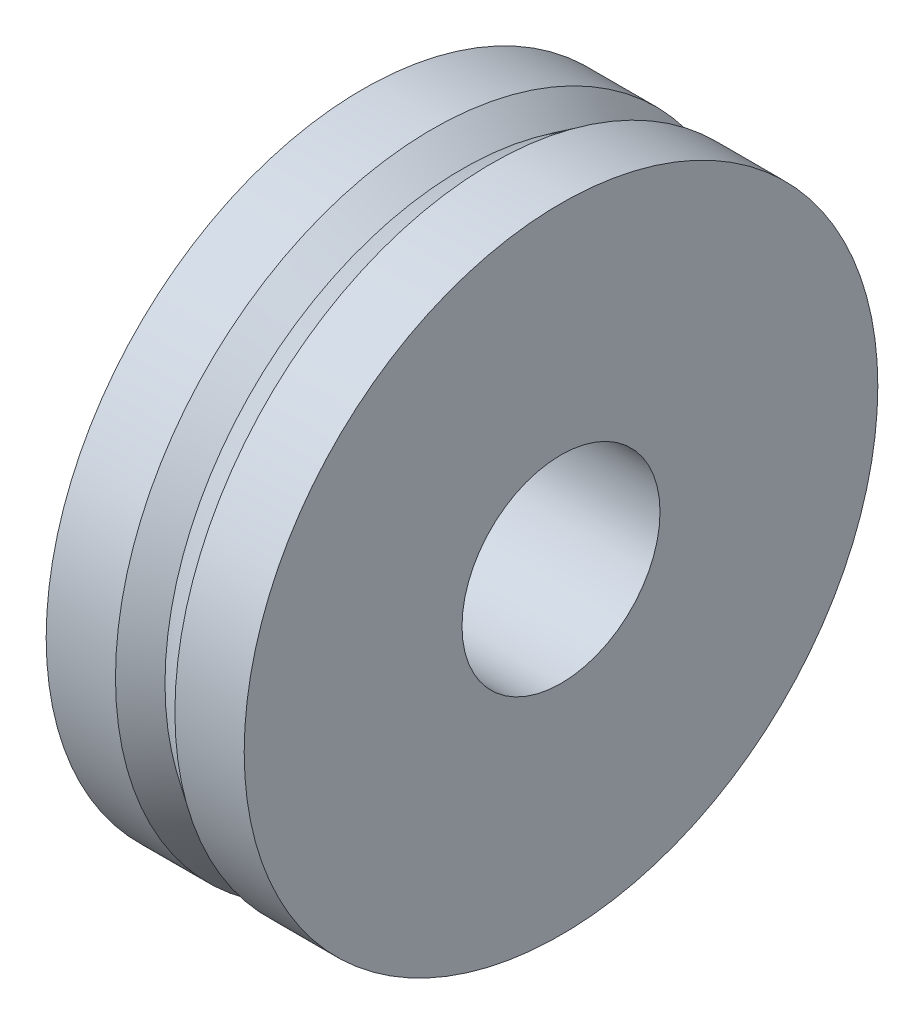
from build123d import *

# Parameters (mm, degrees)
SKETCH1_R           = 8
SKETCH1_R_2         = 2.5
BOSS_EXTRUDE1_DEPTH = 5


with BuildPart() as part:
    # Sketch1 → Boss-Extrude1 (new body)
    with BuildSketch(Plane(origin=(0, 0, 0), x_dir=(0, 0, -1), z_dir=(1, 0, 0))):
        Circle(SKETCH1_R)
        Circle(SKETCH1_R_2, mode=Mode.SUBTRACT)
    extrude(amount=BOSS_EXTRUDE1_DEPTH)

    # Sketch2 → Cut-Revolve1 (revolve, cut)
    with BuildSketch(Plane(origin=(0, 0, 0), x_dir=(1, 0, 0), z_dir=(0, 1, 0))):
        Polygon((1.75, 8), (2.5, 7.5), (3.25, 8), align=None)
    revolve(axis=Axis((0, 0, 0), (1, 0, 0)), mode=Mode.SUBTRACT)


solid = part.part
